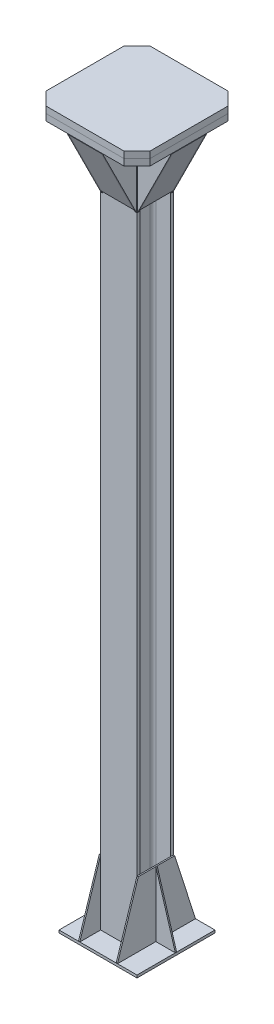
from build123d import *

# Parameters (mm, degrees)
CZ_ON_KONSTRUKCYJNY1_DEPTH        = 2720
SZKIC4_W                          = 300
SZKIC4_H                          = 300
DODANIE_WYCI_GNI_CIE1_DEPTH       = 10
SZKIC6_W                          = 400
SZKIC6_H                          = 400
DODANIE_WYCI_GNI_CIE2_DEPTH       = 25
SFAZOWANIE1_SIZE                  = 50
WYCI_GNI_CIE_CIENKA_CIANKA2_DEPTH = 126
DODANIE_WYCI_GNI_CIE4_DEPTH       = 5
SZYK_KO_OWY1_COUNT                = 4
DODANIE_WYCI_GNI_CIE5_DEPTH       = 5
DODANIE_WYCI_GNI_CIE6_DEPTH       = 2.5


with BuildPart() as part:
    # Sketch11 → Człon konstrukcyjny1 (new body)
    with BuildSketch(Plane(origin=(0, 0, 0), x_dir=(-1, 0, 0), z_dir=(0, 1, 0))):
        with BuildLine():
            Line((-70, -70), (-70, -58))
            Line((-70, -58), (-15.5, -58))
            ThreePointArc((-15.5, -58), (-7.014718626, -54.485281374), (-3.5, -46))
            Line((-3.5, -46), (-3.5, 46))
            ThreePointArc((-3.5, 46), (-7.014718626, 54.485281374), (-15.5, 58))
            Line((-15.5, 58), (-70, 58))
            Line((-70, 58), (-70, 70))
            Line((-70, 70), (70, 70))
            Line((70, 70), (70, 58))
            Line((70, 58), (15.5, 58))
            ThreePointArc((15.5, 58), (7.014718626, 54.485281374), (3.5, 46))
            Line((3.5, 46), (3.5, -46))
            ThreePointArc((3.5, -46), (7.014718626, -54.485281374), (15.5, -58))
            Line((15.5, -58), (70, -58))
            Line((70, -58), (70, -70))
            Line((70, -70), (-70, -70))
        make_face()
    extrude(amount=CZ_ON_KONSTRUKCYJNY1_DEPTH)


with BuildPart() as body_2:
    # Szkic4 → Dodanie-wyciągnięcie1 (new body)
    with BuildSketch(Plane.XZ):
        Rectangle(SZKIC4_W, SZKIC4_H)
    extrude(amount=DODANIE_WYCI_GNI_CIE1_DEPTH)


with BuildPart() as body_3:
    # Szkic6 → Dodanie-wyciągnięcie2 (new body)
    with BuildSketch(Plane(origin=(0, 2720, 0), x_dir=(1, 0, 0), z_dir=(0, 1, 0))):
        Rectangle(SZKIC6_W, SZKIC6_H)
    extrude(amount=DODANIE_WYCI_GNI_CIE2_DEPTH)

    # Sfazowanie1
    sfazowanie1_edges = [body_3.edges().sort_by_distance(p)[0] for p in [
        (200, 2732.5, 200),
        (-200, 2732.5, 200),
        (-200, 2732.5, -200),
        (200, 2732.5, -200),
    ]]
    chamfer(sfazowanie1_edges, length=SFAZOWANIE1_SIZE)


with BuildPart() as body_4:
    # Lustro1: mirrored copy
    add(body_3.part.mirror(Plane.ZX.offset(2745)))


with BuildPart() as body_5:
    # Szkic10 → Wyciągnięcie-cienka ścianka2 (new body)
    with BuildSketch(Plane.ZY.offset(63)):
        Polygon((195, 2720), (70, 2470), (74.472135955, 2467.763932023), (199.472135955, 2717.763932023), align=None)
    extrude(amount=-WYCI_GNI_CIE_CIENKA_CIANKA2_DEPTH)


with BuildPart() as body_6:
    # Szkic12 → Dodanie-wyciągnięcie4 (new body)
    with BuildSketch(Plane.ZY.offset(63)):
        Polygon((70, 2720), (70, 2458.819660113), (200.590169944, 2720), align=None)
    extrude(amount=DODANIE_WYCI_GNI_CIE4_DEPTH)


with BuildPart() as body_7:
    # Lustro2: mirrored copy
    add(body_6.part.mirror(Plane.ZY))


with BuildPart() as szyk_ko_owy1_1:
    # Szyk kołowy1: pattern copy
    add(body_6.part.rotate(Axis((0, 0, 0), (0, 1, 0)), 1 * 360 / SZYK_KO_OWY1_COUNT))


with BuildPart() as szyk_ko_owy1_2:
    # Szyk kołowy1: pattern copy
    add(body_6.part.rotate(Axis((0, 0, 0), (0, 1, 0)), 2 * 360 / SZYK_KO_OWY1_COUNT))


with BuildPart() as szyk_ko_owy1_3:
    # Szyk kołowy1: pattern copy
    add(body_6.part.rotate(Axis((0, 0, 0), (0, 1, 0)), 3 * 360 / SZYK_KO_OWY1_COUNT))


with BuildPart() as szyk_ko_owy1_4:
    # Szyk kołowy1: pattern copy
    add(body_7.part.rotate(Axis((0, 0, 0), (0, 1, 0)), 1 * 360 / SZYK_KO_OWY1_COUNT))


with BuildPart() as szyk_ko_owy1_5:
    # Szyk kołowy1: pattern copy
    add(body_7.part.rotate(Axis((0, 0, 0), (0, 1, 0)), 2 * 360 / SZYK_KO_OWY1_COUNT))


with BuildPart() as szyk_ko_owy1_6:
    # Szyk kołowy1: pattern copy
    add(body_7.part.rotate(Axis((0, 0, 0), (0, 1, 0)), 3 * 360 / SZYK_KO_OWY1_COUNT))


with BuildPart() as szyk_ko_owy1_7:
    # Szyk kołowy1: pattern copy
    add(body_5.part.rotate(Axis((0, 0, 0), (0, 1, 0)), 1 * 360 / SZYK_KO_OWY1_COUNT))


with BuildPart() as szyk_ko_owy1_8:
    # Szyk kołowy1: pattern copy
    add(body_5.part.rotate(Axis((0, 0, 0), (0, 1, 0)), 2 * 360 / SZYK_KO_OWY1_COUNT))


with BuildPart() as szyk_ko_owy1_9:
    # Szyk kołowy1: pattern copy
    add(body_5.part.rotate(Axis((0, 0, 0), (0, 1, 0)), 3 * 360 / SZYK_KO_OWY1_COUNT))


with BuildPart() as body_17:
    # Szkic18 → Dodanie-wyciągnięcie5 (new body)
    with BuildSketch(Plane(origin=(70, 0, 0), x_dir=(0, 0, -1), z_dir=(1, 0, 0))):
        Polygon((-150, 0), (-70, 250), (70, 250), (150, 0), align=None)
    extrude(amount=DODANIE_WYCI_GNI_CIE5_DEPTH)


with BuildPart() as body_18:
    # Szkic20 → Dodanie-wyciągnięcie6 (new body, symmetric)
    with BuildSketch(Plane.XY):
        Polygon((75, 250), (150, 0), (75, 0), align=None)
    extrude(amount=DODANIE_WYCI_GNI_CIE6_DEPTH, both=True)


with BuildPart() as body_19:
    # Lustro4: mirrored copy
    add(body_17.part.mirror(Plane(origin=(0, 0, 0), x_dir=(0, 0, 1), z_dir=(1, 0, 0))))


with BuildPart() as body_20:
    # Lustro4 2: mirrored copy
    add(body_18.part.mirror(Plane(origin=(0, 0, 0), x_dir=(0, 0, 1), z_dir=(1, 0, 0))))


solid = Compound([part.part, body_2.part, body_3.part, body_4.part, body_5.part, body_6.part, body_7.part, szyk_ko_owy1_1.part, szyk_ko_owy1_2.part, szyk_ko_owy1_3.part, szyk_ko_owy1_4.part, szyk_ko_owy1_5.part, szyk_ko_owy1_6.part, szyk_ko_owy1_7.part, szyk_ko_owy1_8.part, szyk_ko_owy1_9.part, body_17.part, body_18.part, body_19.part, body_20.part])
